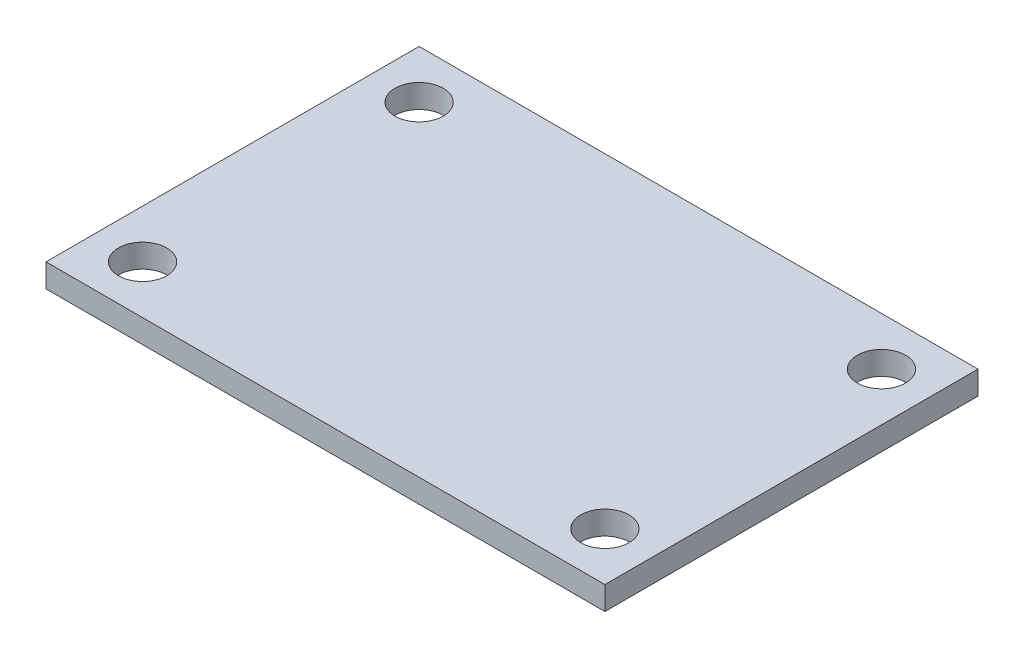
from build123d import *

# Parameters (mm, degrees)
SKETCH1_W           = 38.2
SKETCH1_H           = 25.5
BOSS_EXTRUDE1_DEPTH = 1.6
SKETCH2_R           = 1.65
CUT_EXTRUDE1_DEPTH  = 1.6


with BuildPart() as part:
    # Sketch1 → Boss-Extrude1 (new body)
    with BuildSketch(Plane(origin=(0, 0, 0), x_dir=(1, 0, 0), z_dir=(0, 1, 0))):
        with Locations((19.1, 12.75)):
            Rectangle(SKETCH1_W, SKETCH1_H)
    extrude(amount=BOSS_EXTRUDE1_DEPTH)

    # Sketch2 → Cut-Extrude1 (cut)
    with BuildSketch(Plane(origin=(0, 1.6, 0), x_dir=(1, 0, 0), z_dir=(0, 1, 0))):
        with Locations((34.9, 22.2)):
            Circle(SKETCH2_R)
        with Locations((3.3, 22.2)):
            Circle(SKETCH2_R)
        with Locations((3.3, 3.3)):
            Circle(SKETCH2_R)
        with Locations((34.9, 3.3)):
            Circle(SKETCH2_R)
    extrude(amount=-CUT_EXTRUDE1_DEPTH, mode=Mode.SUBTRACT)


solid = part.part
